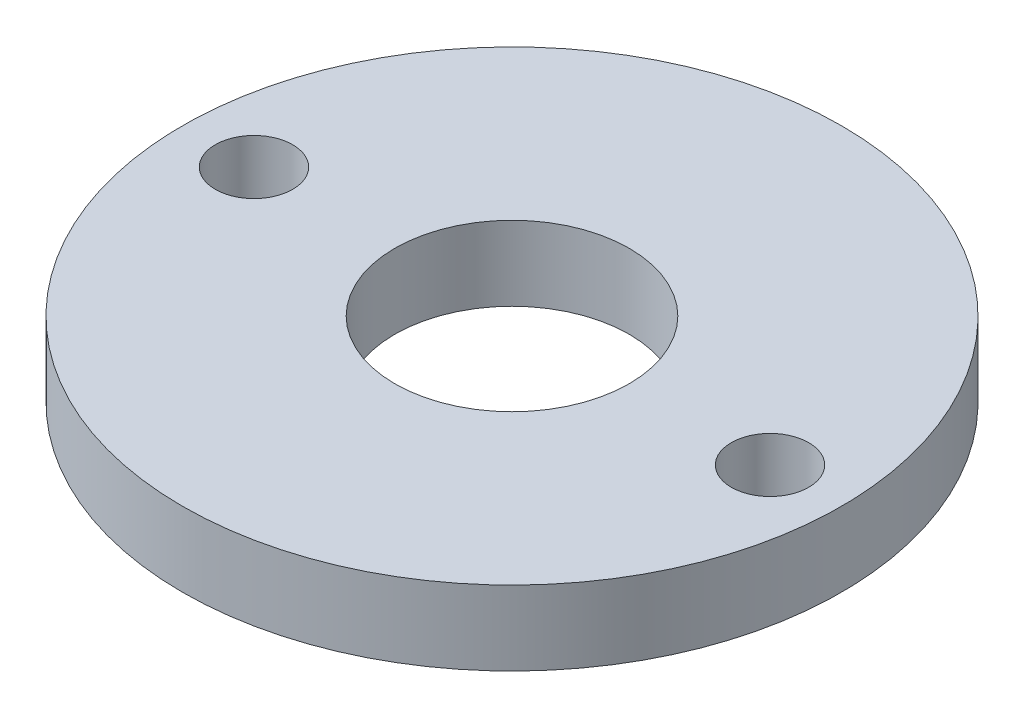
from build123d import *

# Parameters (mm, degrees)
SKETCH1_R           = 14.05
SKETCH1_R_2         = 5
SKETCH1_R_3         = 1.65
BOSS_EXTRUDE1_DEPTH = 3.175


with BuildPart() as part:
    # Sketch1 → Boss-Extrude1 (new body)
    with BuildSketch(Plane(origin=(0, 0, 0), x_dir=(1, 0, 0), z_dir=(0, 1, 0))):
        Circle(SKETCH1_R)
        Circle(SKETCH1_R_2, mode=Mode.SUBTRACT)
        with Locations((11, 0)):
            Circle(SKETCH1_R_3, mode=Mode.SUBTRACT)
        with Locations((-11, 0)):
            Circle(SKETCH1_R_3, mode=Mode.SUBTRACT)
    extrude(amount=BOSS_EXTRUDE1_DEPTH)


solid = part.part
